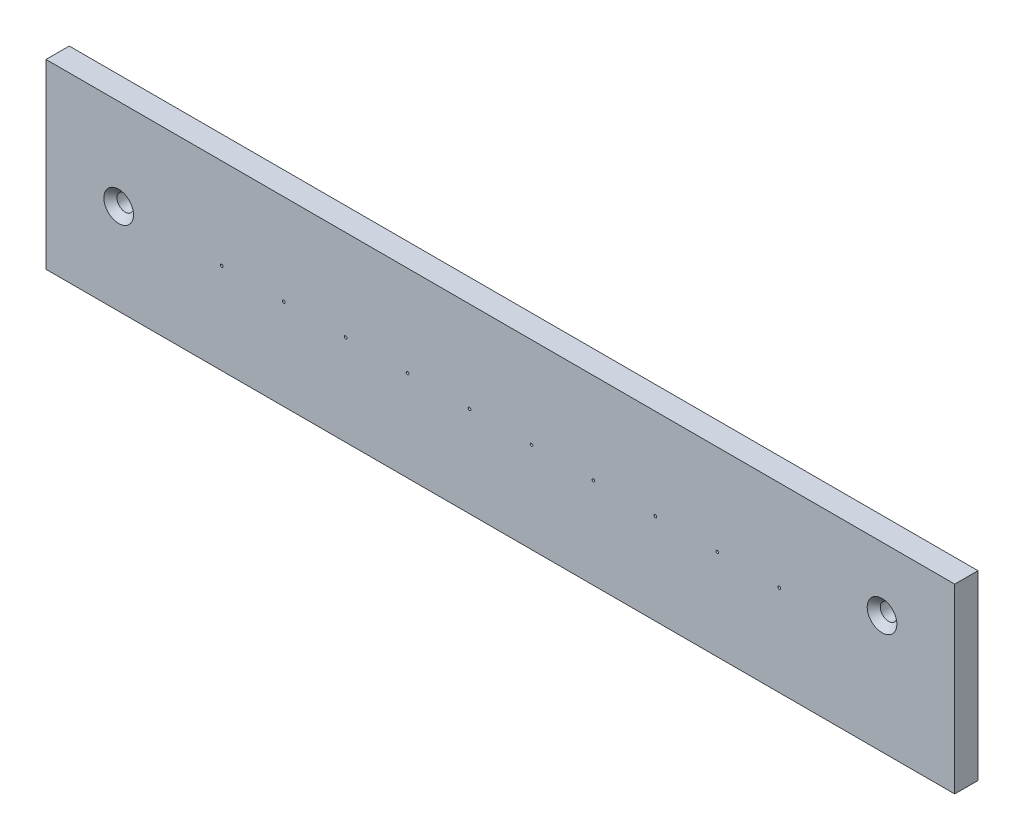
from build123d import *

# Parameters (mm, degrees)
SKETCH1_W           = 158.75
SKETCH1_H           = 31.75
BOSS_EXTRUDE1_DEPTH = 4.064
SKETCH2_R           = 1.4478
CUT_EXTRUDE1_DEPTH  = 5.064
CHAMFER1_SIZE       = 1.143
SKETCH4_R           = 0.24003
CUT_EXTRUDE2_DEPTH  = 5.064
LPATTERN1_COUNT     = 10
LPATTERN1_PITCH     = 10.8204


with BuildPart() as part:
    # Sketch1 → Boss-Extrude1 (new body)
    with BuildSketch(Plane.XY):
        with Locations((47.727419355, 4.199193548)):
            Rectangle(SKETCH1_W, SKETCH1_H)
    extrude(amount=-BOSS_EXTRUDE1_DEPTH)

    # Sketch2 → Cut-Extrude1 (cut, through all)
    with BuildSketch(Plane.XY):
        with Locations((-18.947580645, 4.199193548)):
            Circle(SKETCH2_R)
        with Locations((114.402419355, 8.961693548)):
            Circle(SKETCH2_R)
    extrude(amount=-CUT_EXTRUDE1_DEPTH, mode=Mode.SUBTRACT)

    # Chamfer1
    chamfer1_edges = [part.edges().sort_by_distance(p)[0] for p in [
        (-20.395380645, 4.199193548, 0),
        (112.954619355, 8.961693548, 0),
    ]]
    chamfer(chamfer1_edges, length=CHAMFER1_SIZE)

    # Sketch4 → Cut-Extrude2 (cut, through all)
    with BuildSketch(Plane.XY):
        with Locations((-0.938980645, 4.199193548)):
            Circle(SKETCH4_R)
    cut_extrude2 = extrude(amount=-CUT_EXTRUDE2_DEPTH, mode=Mode.SUBTRACT)

    # LPattern1: Cut-Extrude2 ×10
    with Locations(*[(i * LPATTERN1_PITCH, 0, 0) for i in range(1, LPATTERN1_COUNT)]):
        add(cut_extrude2, mode=Mode.SUBTRACT)


solid = part.part
